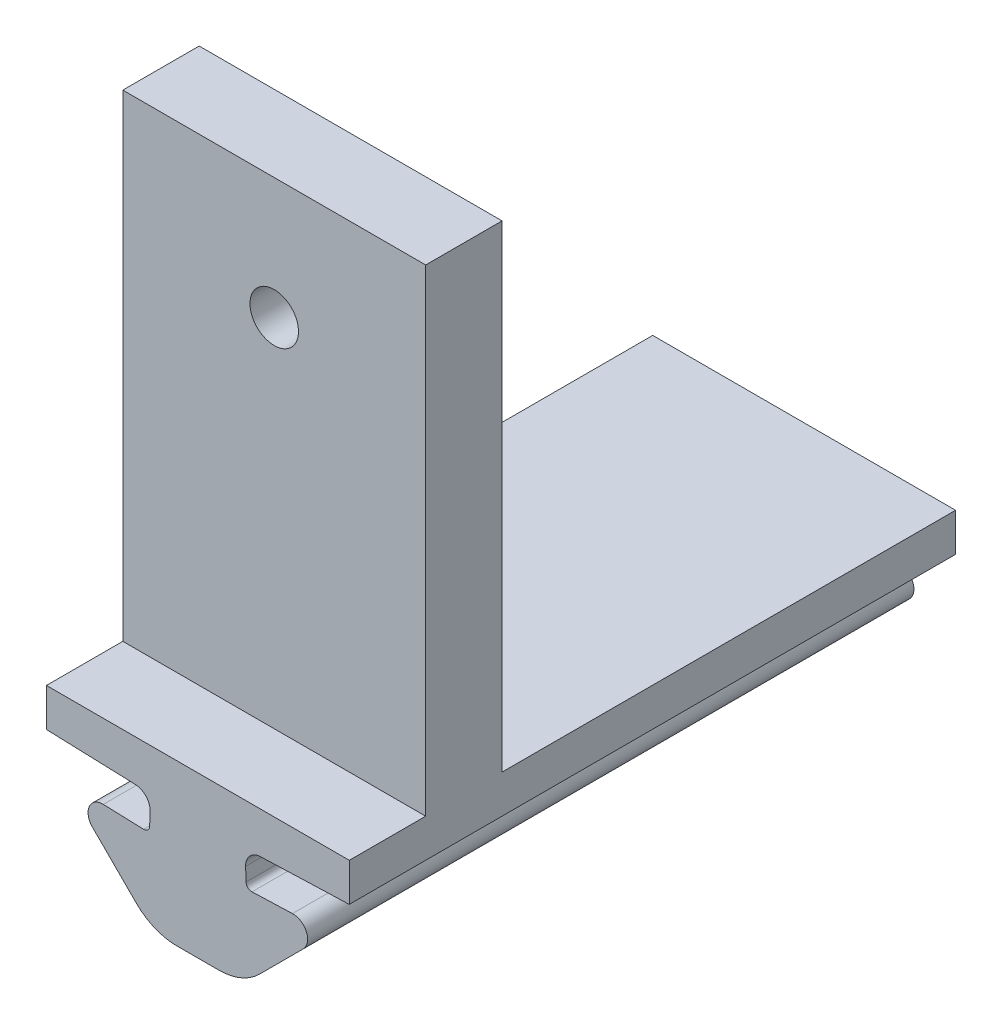
from build123d import *

# Parameters (mm, degrees)
BOSS_EXTRUDE1_DEPTH = 31.75
SKETCH19_W          = 15.860402013
SKETCH19_H          = 31.75
BOSS_EXTRUDE7_DEPTH = 2
SKETCH23_W          = 15.860402013
SKETCH23_H          = 4
BOSS_EXTRUDE8_DEPTH = 25
SKETCH24_R          = 1.27
CUT_EXTRUDE1_DEPTH  = 9


with BuildPart() as part:
    # Sketch2 → Boss-Extrude1 (new body)
    with BuildSketch(Plane.XY):
        with BuildLine():
            Line((-50.375618534, 45.609862895), (-50.351188886, 46.309436474))
            ThreePointArc((-50.351188886, 46.309436474), (-50.565618587, 46.88295476), (-51.12278195, 47.136868733))
            Line((-51.12278195, 47.136868733), (-55.780902554, 47.299533889))
            Line((-55.780902554, 47.299533889), (-47.850701548, 47.299533889))
            Line((-47.850701548, 47.299533889), (-47.850701548, 40.900752235))
            Line((-47.850701548, 40.900752235), (-48.952946324, 40.900752235))
            ThreePointArc((-48.952946324, 40.900752235), (-50.100996621, 41.129113637), (-51.074266668, 41.779431891))
            Line((-51.074266668, 41.779431891), (-53.375146928, 44.080312152))
            ThreePointArc((-53.375146928, 44.080312152), (-53.536830204, 44.931922499), (-52.803734096, 45.394471696))
            Line((-52.803734096, 45.394471696), (-50.685905631, 45.320515496))
            ThreePointArc((-50.685905631, 45.320515496), (-50.470836274, 45.400926634), (-50.375618534, 45.609862895))
        make_face()
    boss_extrude1 = extrude(amount=BOSS_EXTRUDE1_DEPTH)

    # Mirror2: Boss-Extrude1 across plane
    add(boss_extrude1.mirror(Plane(origin=(-47.850701548, 40.900752235, 31.75), x_dir=(0, 0, 1), z_dir=(-1, 0, 0))))

    # Sketch19 → Boss-Extrude7 (add)
    with BuildSketch(Plane(origin=(0, 47.299533889, 0), x_dir=(1, 0, 0), z_dir=(0, 1, 0))):
        with Locations((-47.850701548, -15.875)):
            Rectangle(SKETCH19_W, SKETCH19_H)
    extrude(amount=BOSS_EXTRUDE7_DEPTH)

    # Sketch23 → Boss-Extrude8 (add)
    with BuildSketch(Plane(origin=(0, 49.299533889, 0), x_dir=(1, 0, 0), z_dir=(0, 1, 0))):
        with Locations((-47.850701548, -25.75)):
            Rectangle(SKETCH23_W, SKETCH23_H)
    extrude(amount=BOSS_EXTRUDE8_DEPTH)

    # Sketch24 → Cut-Extrude1 (cut, through all)
    with BuildSketch(Plane(origin=(0, 0, 23.75), x_dir=(-1, 0, 0), z_dir=(0, 0, -1))):
        with Locations((47.850701548, 67.949533889)):
            Circle(SKETCH24_R)
    extrude(amount=-CUT_EXTRUDE1_DEPTH, mode=Mode.SUBTRACT)


solid = part.part
